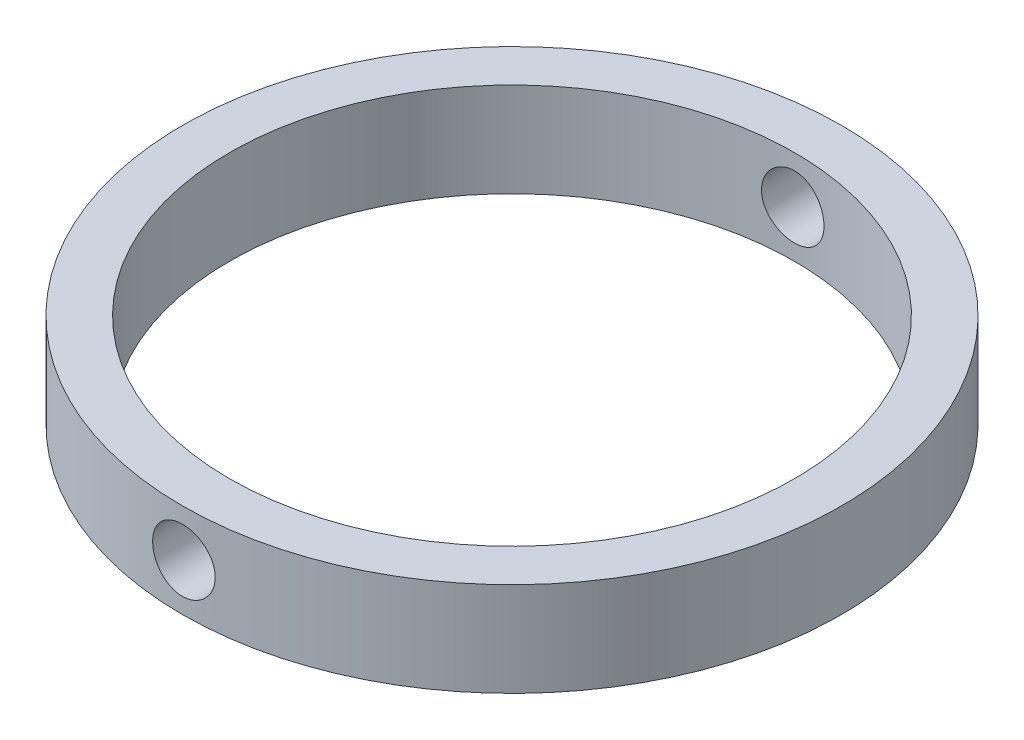
from build123d import *

# Parameters (mm, degrees)
SKETCH1_R               = 44.45
SKETCH1_R_2             = 38.1
BOSS_EXTRUDE1_DEPTH     = 12.7
SKETCH2_R               = 4.2164
CUT_EXTRUDE1_DEPTH      = 45.45
CUT_EXTRUDE1_DEPTH_BACK = 45.45


with BuildPart() as part:
    # Sketch1 → Boss-Extrude1 (new body)
    with BuildSketch(Plane(origin=(0, 0, 0), x_dir=(1, 0, 0), z_dir=(0, 1, 0))):
        Circle(SKETCH1_R)
        Circle(SKETCH1_R_2, mode=Mode.SUBTRACT)
    extrude(amount=BOSS_EXTRUDE1_DEPTH)

    # Sketch2 → Cut-Extrude1 (cut, two sides)
    with BuildSketch(Plane.XY) as cut_extrude1_sk:
        with Locations((0, 6.35)):
            Circle(SKETCH2_R)
    extrude(amount=CUT_EXTRUDE1_DEPTH, mode=Mode.SUBTRACT)
    extrude(cut_extrude1_sk.sketch, amount=-CUT_EXTRUDE1_DEPTH_BACK, mode=Mode.SUBTRACT)


solid = part.part
